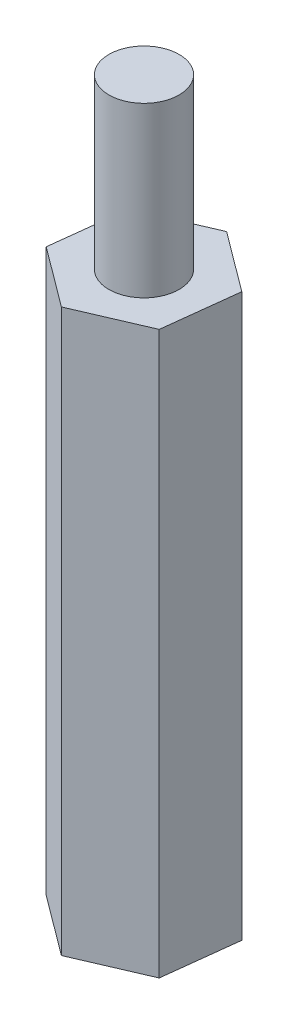
from build123d import *

# Parameters (mm, degrees)
EXTRUDE_1_DEPTH     = 20
SKETCH_2_R          = 1.25
EXTRUDE_2_DEPTH     = 6
SKETCH_3_R          = 1.25
CUT_EXTRUDE_1_DEPTH = 6


with BuildPart() as part:
    # 草图1 → 凸台-拉伸1 (new body)
    with BuildSketch(Plane(origin=(0, 0, 0), x_dir=(1, 0, 0), z_dir=(0, 1, 0))):
        Polygon((2.125123473, -1.583145674), (2.433606108, 1.048838076), (0.308482635, 2.631983751), (-2.125123473, 1.583145674), (-2.433606108, -1.048838076), (-0.308482635, -2.631983751), align=None)
    extrude(amount=EXTRUDE_1_DEPTH)

    # 草图2 → 凸台-拉伸2 (add)
    with BuildSketch(Plane(origin=(0, 20, 0), x_dir=(1, 0, 0), z_dir=(0, 1, 0))):
        Circle(SKETCH_2_R)
    extrude(amount=EXTRUDE_2_DEPTH)

    # 草图3 → 切除-拉伸1 (cut)
    with BuildSketch(Plane.XZ):
        Circle(SKETCH_3_R)
    extrude(amount=-CUT_EXTRUDE_1_DEPTH, mode=Mode.SUBTRACT)


solid = part.part
